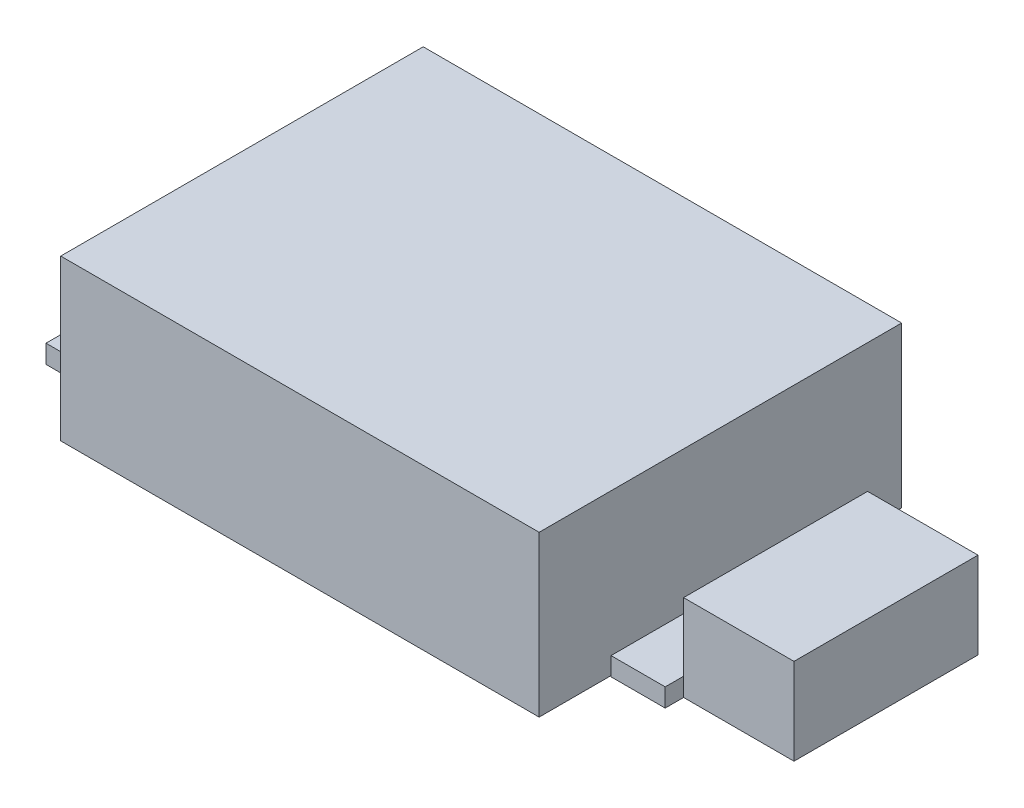
from build123d import *

# Parameters (mm, degrees)
SKETCH_1_W        = 4
SKETCH_1_H        = 13.3
EXTRUDE_1_DEPTH   = 1
SKETCH_1_W_2      = 2.942731278
SKETCH_1_H_2      = 12
EXTRUDE_1_2_DEPTH = 1
EXTRUDE_2_DEPTH   = 8.7
SKETCH_1_5_W      = 6
SKETCH_1_5_H      = 10
EXTRUDE_3_DEPTH   = 4.7


with BuildPart() as part:
    # Эскиз1 → Бобышка-Вытянуть1 (new body)
    with BuildSketch(Plane(origin=(0, 0, 0), x_dir=(1, 0, 0), z_dir=(0, 1, 0))):
        with Locations((-15, 0)):
            Rectangle(SKETCH_1_W, SKETCH_1_H)
    extrude(amount=EXTRUDE_1_DEPTH)

    # Эскиз1<4> → Бобышка-Вытянуть2 (add)
    with BuildSketch(Plane(origin=(0, 0, 0), x_dir=(1, 0, 0), z_dir=(0, 1, 0))):
        Polygon((13, 5), (13, 9.85), (-13, 9.85), (-13, 6.65), (-13, -6.65), (-13, -9.85), (13, -9.85), (13, -5), align=None)
    extrude(amount=EXTRUDE_2_DEPTH)


with BuildPart() as body_2:
    # Эскиз1 → Extrude 1 2 (new body)
    with BuildSketch(Plane(origin=(0, 0, 0), x_dir=(1, 0, 0), z_dir=(0, 1, 0))):
        with Locations((14.528634361, 0)):
            Rectangle(SKETCH_1_W_2, SKETCH_1_H_2)
    extrude(amount=EXTRUDE_1_2_DEPTH)

    # Эскиз1<5> → Бобышка-Вытянуть3 (add)
    with BuildSketch(Plane(origin=(0, 0, 0), x_dir=(1, 0, 0), z_dir=(0, 1, 0))):
        with Locations((19, 0)):
            Rectangle(SKETCH_1_5_W, SKETCH_1_5_H)
    extrude(amount=EXTRUDE_3_DEPTH)


solid = Compound([part.part, body_2.part])
